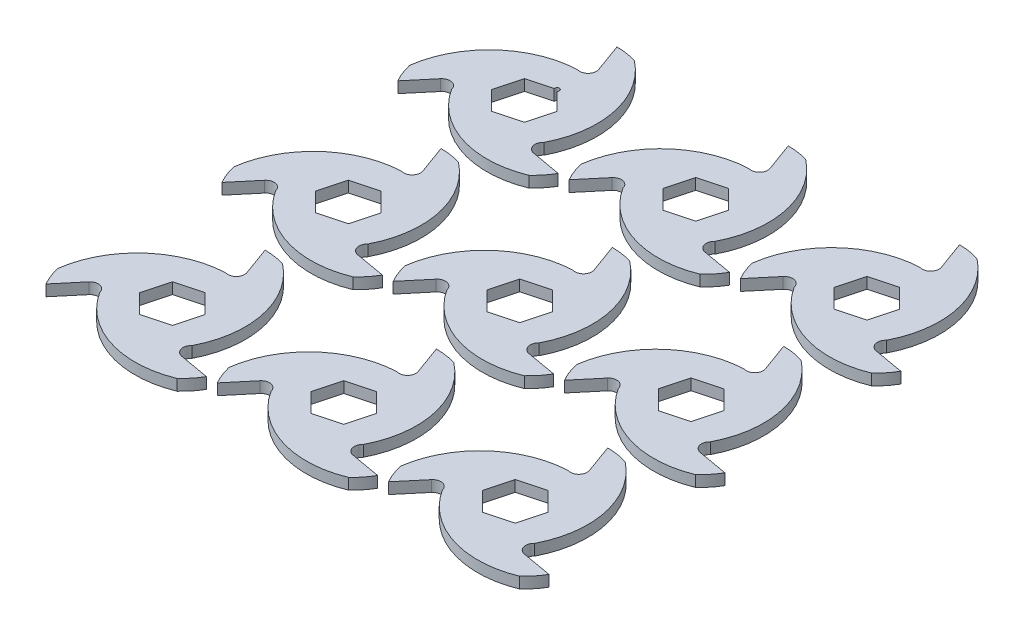
from build123d import *

# Parameters (mm, degrees)
BOSS_EXTRUDE2_DEPTH = 3.048
CUT_EXTRUDE1_DEPTH  = 7.096
LPATTERN1_COUNT     = 3
LPATTERN1_PITCH     = 96.52
LPATTERN1_2_COUNT   = 3
LPATTERN1_2_PITCH   = 93.98
SKETCH4_R           = 1.27
CUT_EXTRUDE2_DEPTH  = 7.096


with BuildPart() as part:
    # Sketch2 → Boss-Extrude2 (new body, symmetric)
    with BuildSketch(Plane(origin=(0, 0, 0), x_dir=(1, 0, 0), z_dir=(0, 1, 0))):
        with BuildLine():
            Line((0, 50.8), (5.699182497, 35.141624781))
            ThreePointArc((5.699182497, 35.141624781), (4.697625818, 30.400196659), (0, 29.21))
            ThreePointArc((0, 29.21), (-40.712457699, 16.982230342), (-43.994090512, -25.4))
            Line((-43.994090512, -25.4), (-33.283131039, -12.635175567))
            ThreePointArc((-33.283131039, -12.635175567), (-28.676155496, -11.131835033), (-25.296602045, -14.605))
            ThreePointArc((-25.296602045, -14.605), (5.64918596, -43.749137789), (43.994090512, -25.4))
            Line((43.994090512, -25.4), (27.583948542, -22.506449213))
            ThreePointArc((27.583948542, -22.506449213), (23.978529677, -19.268361626), (25.296602045, -14.605))
            ThreePointArc((25.296602045, -14.605), (35.063271738, 26.766907447), (0, 50.8))
        make_face()
        Polygon((3.795502832, 14.16500941), (14.16500941, 3.795502832), (10.369506578, -10.369506578), (-3.795502832, -14.16500941), (-14.16500941, -3.795502832), (-10.369506578, 10.369506578), align=None, mode=Mode.SUBTRACT)
    extrude(amount=BOSS_EXTRUDE2_DEPTH, both=True)

    # Sketch3 → Cut-Extrude1 (cut, through all)
    with BuildSketch(Plane(origin=(0, 3.048, 0), x_dir=(1, 0, 0), z_dir=(0, 1, 0))):
        with BuildLine():
            ThreePointArc((0, 29.21), (-36.786884898, 21.158593478), (-48.137903328, -14.747595795))
            ThreePointArc((-48.137903328, -14.747595795), (-32.049598102, 15.970797155), (0, 29.21))
        make_face()
        with BuildLine():
            ThreePointArc((11.297159061, 49.062445064), (29.855915106, 19.77036756), (25.296602045, -14.605))
            ThreePointArc((25.296602045, -14.605), (36.717321909, 21.279080109), (11.297159061, 49.062445064))
        make_face()
        with BuildLine():
            ThreePointArc((-25.296602045, -14.605), (0.069562989, -42.437673587), (36.840744267, -34.314849269))
            ThreePointArc((36.840744267, -34.314849269), (2.193682996, -35.741164715), (-25.296602045, -14.605))
        make_face()
    extrude(amount=-CUT_EXTRUDE1_DEPTH, mode=Mode.SUBTRACT)


with BuildPart() as lpattern1_1:
    # LPattern1: pattern copy
    add(part.part.moved(Location(Vector(0, 0, 1) * (1 * LPATTERN1_PITCH))))


with BuildPart() as lpattern1_2:
    # LPattern1: pattern copy
    add(part.part.moved(Location(Vector(0, 0, 1) * (2 * LPATTERN1_PITCH))))


with BuildPart() as lpattern1_2_1:
    # LPattern1 2: pattern copy
    add(part.part.moved(Location(Vector(1, 0, 0) * (1 * LPATTERN1_2_PITCH))))


with BuildPart() as lpattern1_2_2:
    # LPattern1 2: pattern copy
    add(part.part.moved(Location(Vector(1, 0, 0) * (2 * LPATTERN1_2_PITCH))))


with BuildPart() as lpattern1_2_3:
    # LPattern1 2: pattern copy
    add(lpattern1_1.part.moved(Location(Vector(1, 0, 0) * (1 * LPATTERN1_2_PITCH))))


with BuildPart() as lpattern1_2_4:
    # LPattern1 2: pattern copy
    add(lpattern1_1.part.moved(Location(Vector(1, 0, 0) * (2 * LPATTERN1_2_PITCH))))


with BuildPart() as lpattern1_2_5:
    # LPattern1 2: pattern copy
    add(lpattern1_2.part.moved(Location(Vector(1, 0, 0) * (1 * LPATTERN1_2_PITCH))))


with BuildPart() as lpattern1_2_6:
    # LPattern1 2: pattern copy
    add(lpattern1_2.part.moved(Location(Vector(1, 0, 0) * (2 * LPATTERN1_2_PITCH))))


with BuildPart() as part_1:
    add(part.part)

    # Sketch4 → Cut-Extrude2 (cut, through all)
    with BuildSketch(Plane(origin=(0, 3.048, 0), x_dir=(1, 0, 0), z_dir=(0, 1, 0))):
        with Locations((3.795502832, 14.16500941)):
            Circle(SKETCH4_R)
    extrude(amount=-CUT_EXTRUDE2_DEPTH, mode=Mode.SUBTRACT)


solid = Compound([lpattern1_1.part, lpattern1_2.part, lpattern1_2_1.part, lpattern1_2_2.part, lpattern1_2_3.part, lpattern1_2_4.part, lpattern1_2_5.part, lpattern1_2_6.part, part_1.part])
